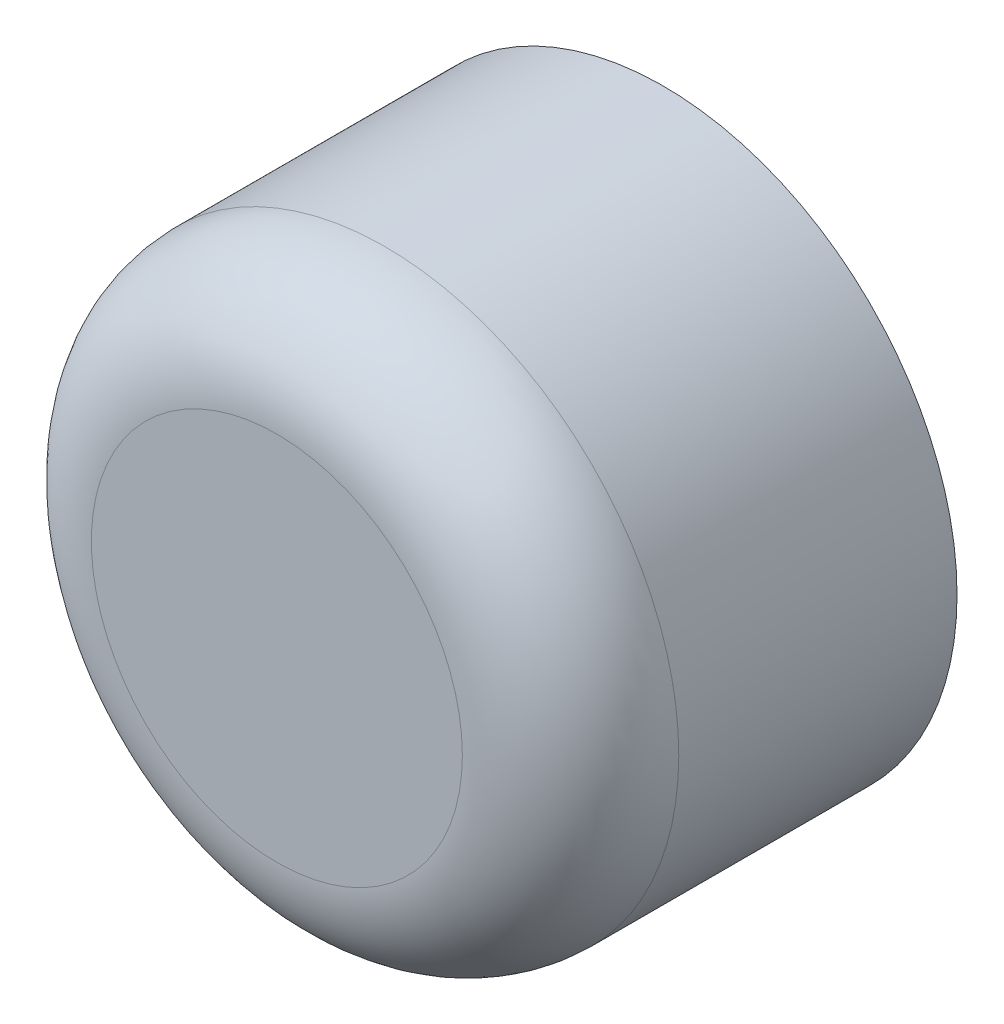
from build123d import *

# Parameters (mm, degrees)
SKETCH_1_R          = 19
EXTRUDE_1_DEPTH     = 25
SKETCH_2_R          = 10
CUT_EXTRUDE_1_DEPTH = 5
SKETCH_3_R          = 3
CUT_EXTRUDE_2_DEPTH = 15
CUT_EXTRUDE_3_REACH = 21
SKETCH_4_R          = 1.1
FILLET_1_R          = 7


with BuildPart() as part:
    # 草圖1 → 填料-伸長1 (new body)
    with BuildSketch(Plane.XY):
        Circle(SKETCH_1_R)
    extrude(amount=EXTRUDE_1_DEPTH)

    # 草圖2 → 除料-伸長1 (cut)
    with BuildSketch(Plane(origin=(0, 0, 0), x_dir=(-1, 0, 0), z_dir=(0, 0, -1))):
        Circle(SKETCH_2_R)
    extrude(amount=-CUT_EXTRUDE_1_DEPTH, mode=Mode.SUBTRACT)

    # 草圖3 → 除料-伸長2 (cut)
    with BuildSketch(Plane(origin=(0, 0, 5), x_dir=(-1, 0, 0), z_dir=(0, 0, -1))):
        Circle(SKETCH_3_R)
    extrude(amount=-CUT_EXTRUDE_2_DEPTH, mode=Mode.SUBTRACT)

    # 草圖4 → 除料-伸長3 (cut, up to next)
    with BuildSketch(Plane(origin=(0, 0, 0), x_dir=(1, 0, 0), z_dir=(0, 1, 0)), mode=Mode.PRIVATE) as cut_extrude_3_sk1:
        with Locations((0, -10)):
            Circle(SKETCH_4_R)
    cut_extrude_3_tool1 = extrude(cut_extrude_3_sk1.sketch, amount=-CUT_EXTRUDE_3_REACH, mode=Mode.PRIVATE) & part.part
    add(cut_extrude_3_tool1.solids().sort_by_distance((0, 0, 10))[0], mode=Mode.SUBTRACT)

    # 圓角1
    fillet_1_edges = [part.edges().sort_by_distance(p)[0] for p in [
        (-19, 0, 25),
    ]]
    fillet(fillet_1_edges, radius=FILLET_1_R)


solid = part.part
